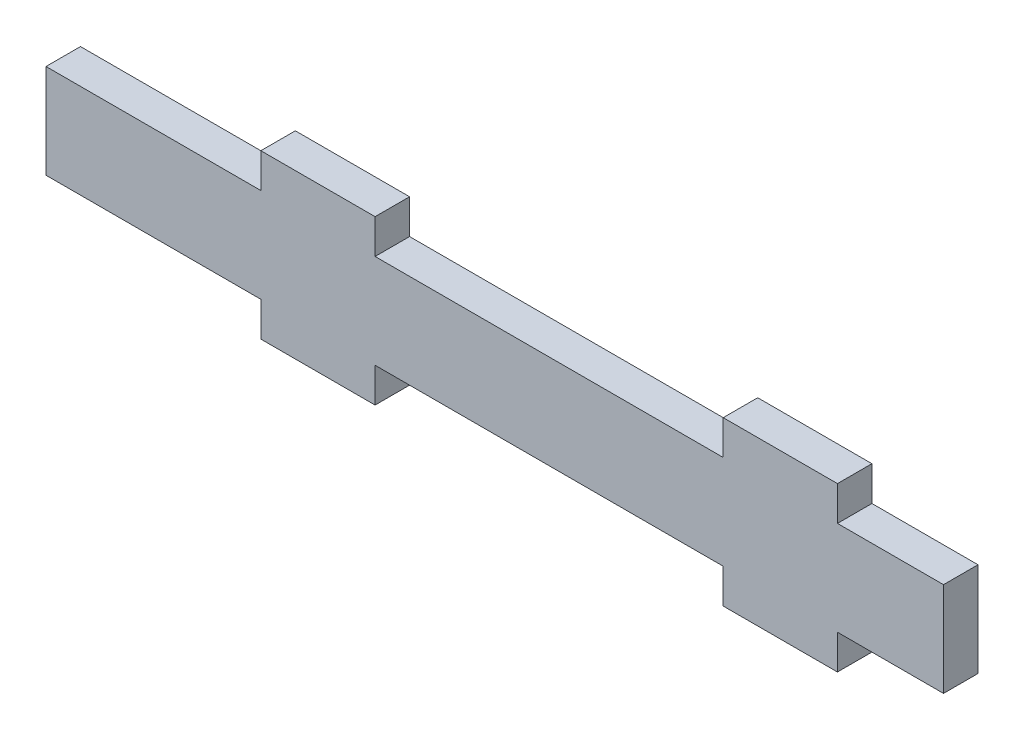
from build123d import *

# Parameters (mm, degrees)
SKETCH1_W           = 82.5
SKETCH1_H           = 8.66
SKETCH1_W_2         = 10.5
SKETCH1_H_2         = 3.17
BOSS_EXTRUDE1_DEPTH = 3.17


with BuildPart() as part:
    # Sketch1 → Boss-Extrude1 (new body)
    with BuildSketch(Plane.XY):
        with Locations((41.25, 4.33)):
            Rectangle(SKETCH1_W, SKETCH1_H)
        with Locations((25, 10.245)):
            Rectangle(SKETCH1_W_2, SKETCH1_H_2)
        with Locations((67.5, 10.245)):
            Rectangle(SKETCH1_W_2, SKETCH1_H_2)
        with Locations((25, -1.585)):
            Rectangle(SKETCH1_W_2, SKETCH1_H_2)
        with Locations((67.5, -1.585)):
            Rectangle(SKETCH1_W_2, SKETCH1_H_2)
    extrude(amount=BOSS_EXTRUDE1_DEPTH)


solid = part.part
